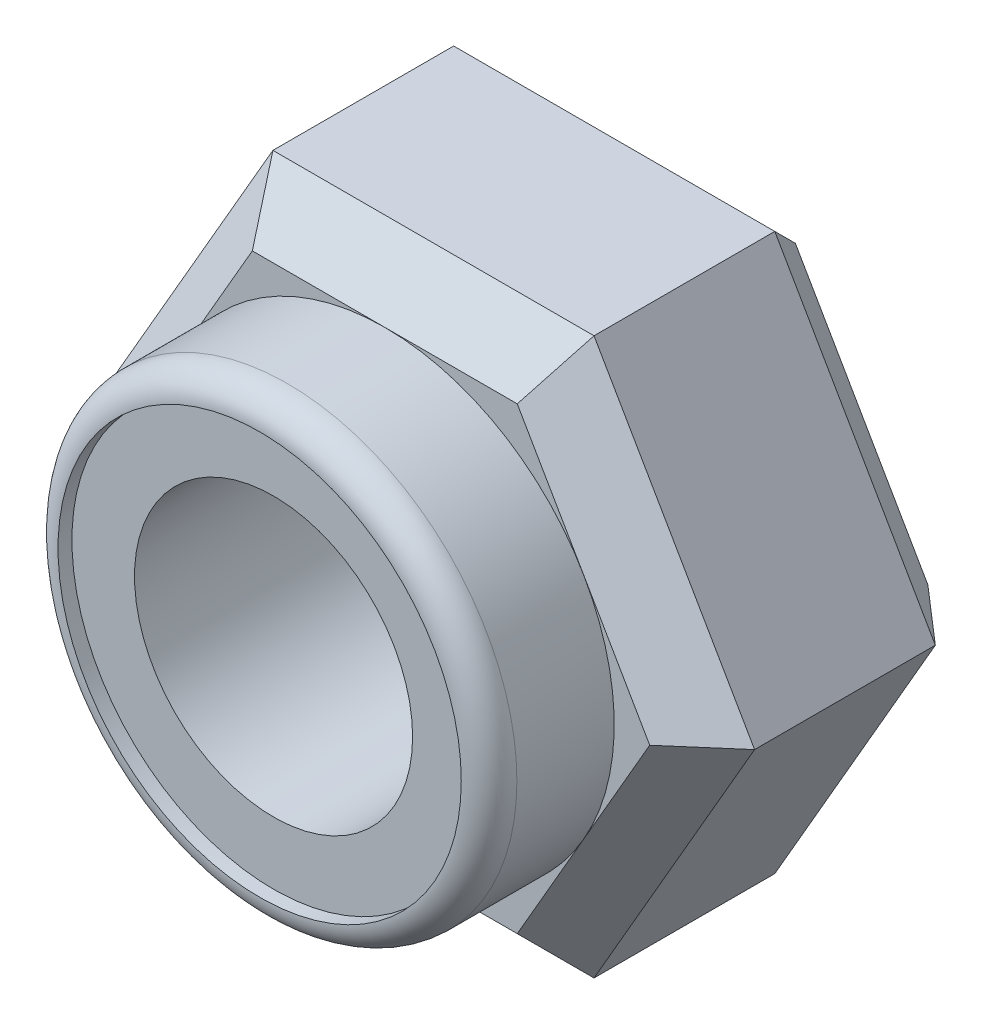
from build123d import *

# Parameters (mm, degrees)
SKETCH1_R           = 1
SHAPE_DEPTH         = 2
CHAMFER_2_SIZE      = 0.35
SKETCH2_R           = 1.65
SKETCH2_R_2         = 1
BOSS_EXTRUDE2_DEPTH = 0.9
FILLET1_R           = 0.2
CUT_EXTRUDE1_START  = -0.1
SKETCH3_R           = 1.45
SKETCH3_R_2         = 1
CUT_EXTRUDE1_DEPTH  = 0.1


with BuildPart() as part:
    # Sketch1 → Shape (new body)
    with BuildSketch(Plane.XY):
        Polygon((-1.154700538, -2), (1.154700538, -2), (2.309401077, 0), (1.154700538, 2), (-1.154700538, 2), (-2.309401077, 0), align=None)
        Circle(SKETCH1_R, mode=Mode.SUBTRACT)
    extrude(amount=SHAPE_DEPTH)

    # Chamfer 2
    chamfer_2_edges = [part.edges().sort_by_distance(p)[0] for p in [
        (1.732050808, -1, 0),
        (0, -2, 0),
        (-1.732050808, -1, 0),
        (-1.732050808, 1, 0),
        (0, 2, 0),
        (1.732050808, 1, 0),
        (1.732050808, 1, 2),
        (1.732050808, -1, 2),
        (0, -2, 2),
        (-1.732050808, -1, 2),
        (-1.732050808, 1, 2),
        (0, 2, 2),
    ]]
    chamfer(chamfer_2_edges, length=CHAMFER_2_SIZE)

    # Sketch2 → Boss-Extrude2 (add)
    with BuildSketch(Plane.XY.offset(2)):
        Circle(SKETCH2_R)
        Circle(SKETCH2_R_2, mode=Mode.SUBTRACT)
    extrude(amount=BOSS_EXTRUDE2_DEPTH)

    # Fillet1
    fillet1_edges = [part.edges().sort_by_distance(p)[0] for p in [
        (-1.65, 0, 2.9),
    ]]
    fillet(fillet1_edges, radius=FILLET1_R)

    # Sketch3 → Cut-Extrude1 (cut)
    with BuildSketch(Plane.XY.offset(2.9).offset(CUT_EXTRUDE1_START)):
        Circle(SKETCH3_R)
        Circle(SKETCH3_R_2, mode=Mode.SUBTRACT)
    extrude(amount=CUT_EXTRUDE1_DEPTH, mode=Mode.SUBTRACT)


solid = part.part
